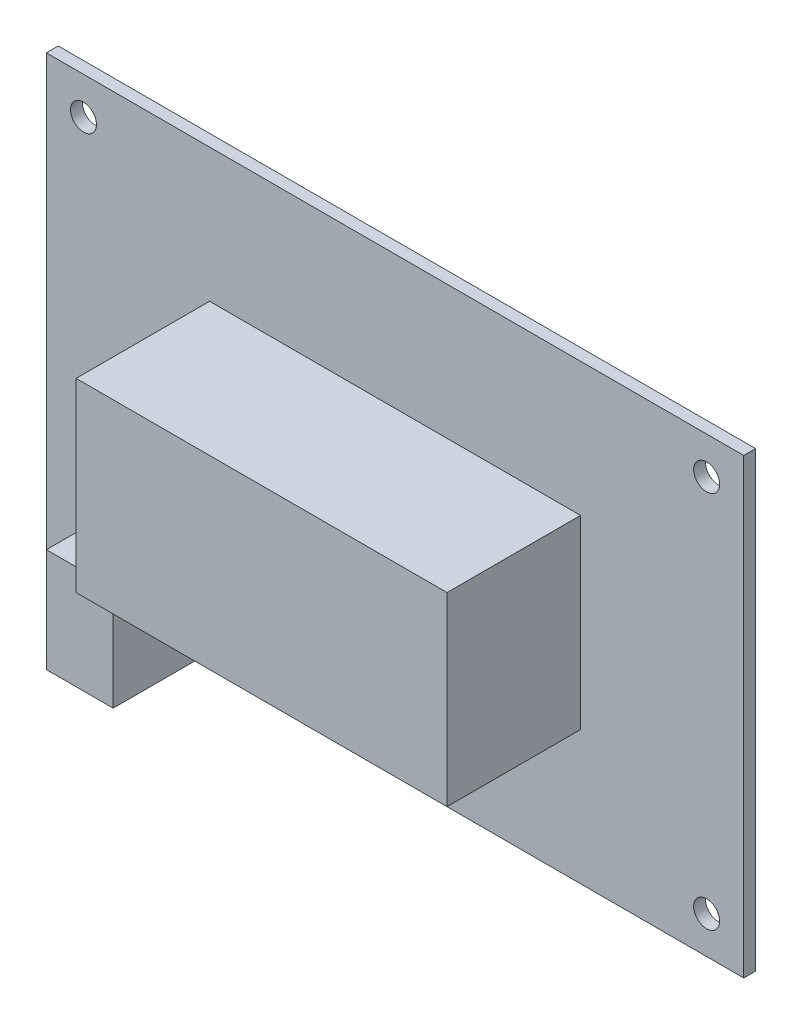
from build123d import *

# Parameters (mm, degrees)
ESQUISSE1_W        = 94
ESQUISSE1_H        = 61
ESQUISSE1_R        = 1.75
BOSS_EXTRU_1_DEPTH = 1.6
ESQUISSE2_W        = 50
ESQUISSE2_H        = 25
BOSS_EXTRU_2_DEPTH = 18
ESQUISSE3_W        = 9
ESQUISSE3_H        = 14
BOSS_EXTRU_3_DEPTH = 11


with BuildPart() as part:
    # Esquisse1 → Boss.-Extru.1 (new body)
    with BuildSketch(Plane.XY):
        Rectangle(ESQUISSE1_W, ESQUISSE1_H)
        with Locations((-42, 25.5)):
            Circle(ESQUISSE1_R, mode=Mode.SUBTRACT)
        with Locations((42, 25.5)):
            Circle(ESQUISSE1_R, mode=Mode.SUBTRACT)
        with Locations((42, -25.5)):
            Circle(ESQUISSE1_R, mode=Mode.SUBTRACT)
        with Locations((-42, -25.5)):
            Circle(ESQUISSE1_R, mode=Mode.SUBTRACT)
    extrude(amount=BOSS_EXTRU_1_DEPTH)

    # Esquisse2 → Boss.-Extru.2 (add)
    with BuildSketch(Plane.XY.offset(1.6)):
        Rectangle(ESQUISSE2_W, ESQUISSE2_H)
    extrude(amount=BOSS_EXTRU_2_DEPTH)

    # Esquisse3 → Boss.-Extru.3 (add)
    with BuildSketch(Plane.XY.offset(1.6)):
        with Locations((-31.5, -23.5)):
            Rectangle(ESQUISSE3_W, ESQUISSE3_H)
    extrude(amount=BOSS_EXTRU_3_DEPTH)


solid = part.part
